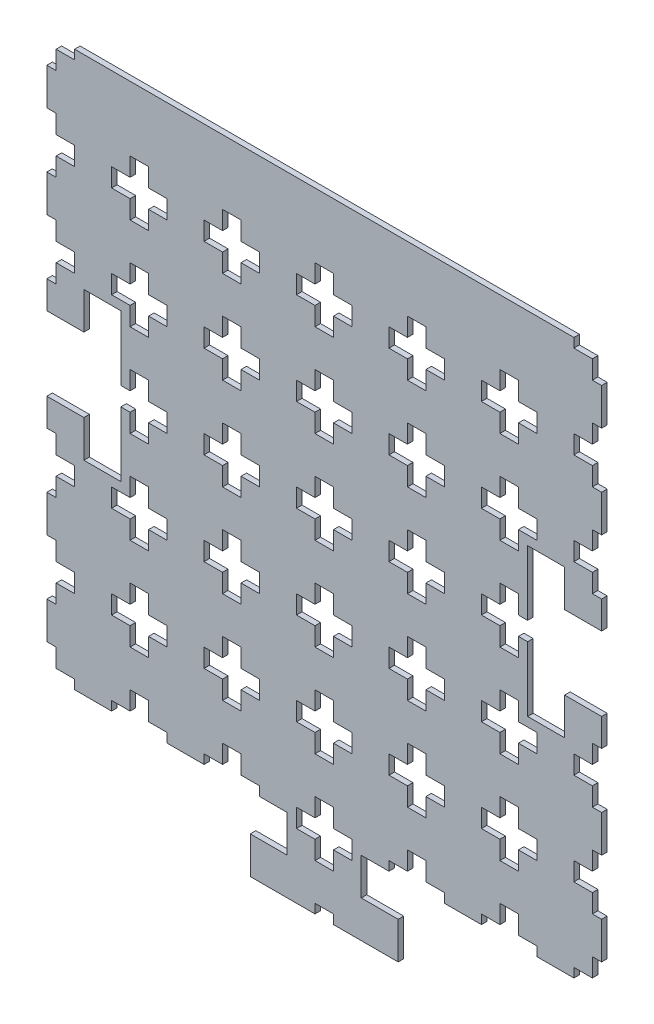
from build123d import *

# Parameters (mm, degrees)
ESQUISSE1_W             = 300
ESQUISSE1_H             = 300
BOSS_EXTRU_1_DEPTH      = 3
BOSS_EXTRU_5_DEPTH      = 3
ENL_V_MAT_EXTRU_4_DEPTH = 4
ENL_V_MAT_EXTRU_5_DEPTH = 4


with BuildPart() as part:
    # Esquisse1 → Boss.-Extru.1 (new body)
    with BuildSketch(Plane.XY):
        with Locations((-68.640329964, 23.061811309)):
            Rectangle(ESQUISSE1_W, ESQUISSE1_H)
    extrude(amount=BOSS_EXTRU_1_DEPTH)

    # Esquisse3 → Boss.-Extru.5 (add)
    with BuildSketch(Plane(origin=(0, 0, 0), x_dir=(-1, 0, 0), z_dir=(0, 0, -1))):
        Polygon((48.640329964, -126.938188691), (48.640329964, -146.938188691), (28.640329964, -146.938188691), (28.640329964, -166.938188691), (108.640329964, -166.938188691), (108.640329964, -146.938188691), (88.640329964, -146.938188691), (88.640329964, -126.938188691), align=None)
    extrude(amount=-BOSS_EXTRU_5_DEPTH)

    # Esquisse4 → Enlèv. mat.-Extru.4 (cut, through all)
    with BuildSketch(Plane.XY.offset(3)):
        Polygon((81.359670036, 3.061811309), (81.359670036, 43.061811309), (61.359670036, 43.061811309), (61.359670036, 63.061811309), (41.359670036, 63.061811309), (41.359670036, -16.938188691), (61.359670036, -16.938188691), (61.359670036, 3.061811309), align=None)
        Polygon((-218.640329964, 43.061811309), (-218.640329964, 3.061811309), (-198.640329964, 3.061811309), (-198.640329964, -16.938188691), (-178.640329964, -16.938188691), (-178.640329964, 63.061811309), (-198.640329964, 63.061811309), (-198.640329964, 43.061811309), align=None)
    extrude(amount=-ENL_V_MAT_EXTRU_4_DEPTH, mode=Mode.SUBTRACT)

    # Esquisse2 → Enlèv. mat.-Extru.5 (cut, through all)
    with BuildSketch(Plane(origin=(0, 0, 0), x_dir=(-1, 0, 0), z_dir=(0, 0, -1))):
        Polygon((-81.359670036, 138.061811309), (-76.359670036, 138.061811309), (-76.359670036, 128.061811309), (-66.359670036, 128.061811309), (-66.359670036, 118.061811309), (-76.359670036, 118.061811309), (-76.359670036, 108.061811309), (-81.359670036, 108.061811309), align=None)
        Polygon((13.640329964, 128.061811309), (13.640329964, 138.061811309), (23.640329964, 138.061811309), (23.640329964, 128.061811309), (33.640329964, 128.061811309), (33.640329964, 118.061811309), (23.640329964, 118.061811309), (23.640329964, 108.061811309), (13.640329964, 108.061811309), (13.640329964, 118.061811309), (3.640329964, 118.061811309), (3.640329964, 128.061811309), align=None)
        Polygon((-81.359670036, 88.061811309), (-76.359670036, 88.061811309), (-76.359670036, 78.061811309), (-66.359670036, 78.061811309), (-66.359670036, 68.061811309), (-76.359670036, 68.061811309), (-76.359670036, 58.061811309), (-81.359670036, 58.061811309), align=None)
        Polygon((-81.359670036, 38.061811309), (-76.359670036, 38.061811309), (-76.359670036, 28.061811309), (-66.359670036, 28.061811309), (-66.359670036, 18.061811309), (-76.359670036, 18.061811309), (-76.359670036, 8.061811309), (-81.359670036, 8.061811309), align=None)
        Polygon((-81.359670036, -11.938188691), (-76.359670036, -11.938188691), (-76.359670036, -21.938188691), (-66.359670036, -21.938188691), (-66.359670036, -31.938188691), (-76.359670036, -31.938188691), (-76.359670036, -41.938188691), (-81.359670036, -41.938188691), align=None)
        Polygon((-81.359670036, -61.938188691), (-76.359670036, -61.938188691), (-76.359670036, -71.938188691), (-66.359670036, -71.938188691), (-66.359670036, -81.938188691), (-76.359670036, -81.938188691), (-76.359670036, -91.938188691), (-81.359670036, -91.938188691), align=None)
        Polygon((-81.359670036, -111.938188691), (-76.359670036, -111.938188691), (-76.359670036, -121.938188691), (-66.359670036, -121.938188691), (-66.359670036, -126.938188691), (-81.359670036, -126.938188691), align=None)
        Polygon((-36.359670036, 128.061811309), (-36.359670036, 138.061811309), (-26.359670036, 138.061811309), (-26.359670036, 128.061811309), (-16.359670036, 128.061811309), (-16.359670036, 118.061811309), (-26.359670036, 118.061811309), (-26.359670036, 108.061811309), (-36.359670036, 108.061811309), (-36.359670036, 118.061811309), (-46.359670036, 118.061811309), (-46.359670036, 128.061811309), align=None)
        Polygon((63.640329964, 128.061811309), (63.640329964, 138.061811309), (73.640329964, 138.061811309), (73.640329964, 128.061811309), (83.640329964, 128.061811309), (83.640329964, 118.061811309), (73.640329964, 118.061811309), (73.640329964, 108.061811309), (63.640329964, 108.061811309), (63.640329964, 118.061811309), (53.640329964, 118.061811309), (53.640329964, 128.061811309), align=None)
        Polygon((113.640329964, 128.061811309), (113.640329964, 138.061811309), (123.640329964, 138.061811309), (123.640329964, 128.061811309), (133.640329964, 128.061811309), (133.640329964, 118.061811309), (123.640329964, 118.061811309), (123.640329964, 108.061811309), (113.640329964, 108.061811309), (113.640329964, 118.061811309), (103.640329964, 118.061811309), (103.640329964, 128.061811309), align=None)
        Polygon((163.640329964, 128.061811309), (163.640329964, 138.061811309), (173.640329964, 138.061811309), (173.640329964, 128.061811309), (183.640329964, 128.061811309), (183.640329964, 118.061811309), (173.640329964, 118.061811309), (173.640329964, 108.061811309), (163.640329964, 108.061811309), (163.640329964, 118.061811309), (153.640329964, 118.061811309), (153.640329964, 128.061811309), align=None)
        Polygon((213.640329964, 128.061811309), (213.640329964, 138.061811309), (223.640329964, 138.061811309), (223.640329964, 128.061811309), (233.640329964, 128.061811309), (233.640329964, 118.061811309), (223.640329964, 118.061811309), (223.640329964, 108.061811309), (213.640329964, 108.061811309), (213.640329964, 118.061811309), (203.640329964, 118.061811309), (203.640329964, 128.061811309), align=None)
        Polygon((13.640329964, 78.061811309), (13.640329964, 88.061811309), (23.640329964, 88.061811309), (23.640329964, 78.061811309), (33.640329964, 78.061811309), (33.640329964, 68.061811309), (23.640329964, 68.061811309), (23.640329964, 58.061811309), (13.640329964, 58.061811309), (13.640329964, 68.061811309), (3.640329964, 68.061811309), (3.640329964, 78.061811309), align=None)
        Polygon((63.640329964, 78.061811309), (63.640329964, 88.061811309), (73.640329964, 88.061811309), (73.640329964, 78.061811309), (83.640329964, 78.061811309), (83.640329964, 68.061811309), (73.640329964, 68.061811309), (73.640329964, 58.061811309), (63.640329964, 58.061811309), (63.640329964, 68.061811309), (53.640329964, 68.061811309), (53.640329964, 78.061811309), align=None)
        Polygon((113.640329964, 78.061811309), (113.640329964, 88.061811309), (123.640329964, 88.061811309), (123.640329964, 78.061811309), (133.640329964, 78.061811309), (133.640329964, 68.061811309), (123.640329964, 68.061811309), (123.640329964, 58.061811309), (113.640329964, 58.061811309), (113.640329964, 68.061811309), (103.640329964, 68.061811309), (103.640329964, 78.061811309), align=None)
        Polygon((163.640329964, 78.061811309), (163.640329964, 88.061811309), (173.640329964, 88.061811309), (173.640329964, 78.061811309), (183.640329964, 78.061811309), (183.640329964, 68.061811309), (173.640329964, 68.061811309), (173.640329964, 58.061811309), (163.640329964, 58.061811309), (163.640329964, 68.061811309), (153.640329964, 68.061811309), (153.640329964, 78.061811309), align=None)
        Polygon((213.640329964, 78.061811309), (213.640329964, 88.061811309), (223.640329964, 88.061811309), (223.640329964, 78.061811309), (233.640329964, 78.061811309), (233.640329964, 68.061811309), (223.640329964, 68.061811309), (223.640329964, 58.061811309), (213.640329964, 58.061811309), (213.640329964, 68.061811309), (203.640329964, 68.061811309), (203.640329964, 78.061811309), align=None)
        Polygon((13.640329964, 28.061811309), (13.640329964, 38.061811309), (23.640329964, 38.061811309), (23.640329964, 28.061811309), (33.640329964, 28.061811309), (33.640329964, 18.061811309), (23.640329964, 18.061811309), (23.640329964, 8.061811309), (13.640329964, 8.061811309), (13.640329964, 18.061811309), (3.640329964, 18.061811309), (3.640329964, 28.061811309), align=None)
        Polygon((63.640329964, 28.061811309), (63.640329964, 38.061811309), (73.640329964, 38.061811309), (73.640329964, 28.061811309), (83.640329964, 28.061811309), (83.640329964, 18.061811309), (73.640329964, 18.061811309), (73.640329964, 8.061811309), (63.640329964, 8.061811309), (63.640329964, 18.061811309), (53.640329964, 18.061811309), (53.640329964, 28.061811309), align=None)
        Polygon((113.640329964, 28.061811309), (113.640329964, 38.061811309), (123.640329964, 38.061811309), (123.640329964, 28.061811309), (133.640329964, 28.061811309), (133.640329964, 18.061811309), (123.640329964, 18.061811309), (123.640329964, 8.061811309), (113.640329964, 8.061811309), (113.640329964, 18.061811309), (103.640329964, 18.061811309), (103.640329964, 28.061811309), align=None)
        Polygon((163.640329964, 28.061811309), (163.640329964, 38.061811309), (173.640329964, 38.061811309), (173.640329964, 28.061811309), (183.640329964, 28.061811309), (183.640329964, 18.061811309), (173.640329964, 18.061811309), (173.640329964, 8.061811309), (163.640329964, 8.061811309), (163.640329964, 18.061811309), (153.640329964, 18.061811309), (153.640329964, 28.061811309), align=None)
        Polygon((213.640329964, 28.061811309), (213.640329964, 38.061811309), (223.640329964, 38.061811309), (223.640329964, 28.061811309), (233.640329964, 28.061811309), (233.640329964, 18.061811309), (223.640329964, 18.061811309), (223.640329964, 8.061811309), (213.640329964, 8.061811309), (213.640329964, 18.061811309), (203.640329964, 18.061811309), (203.640329964, 28.061811309), align=None)
        Polygon((-66.359670036, 173.061811309), (-66.359670036, 168.061811309), (-76.359670036, 168.061811309), (-76.359670036, 158.061811309), (-81.359670036, 158.061811309), (-81.359670036, 173.061811309), align=None)
        Polygon((218.640329964, 158.061811309), (213.640329964, 158.061811309), (213.640329964, 168.061811309), (203.640329964, 168.061811309), (203.640329964, 173.061811309), (218.640329964, 173.061811309), align=None)
        Polygon((13.640329964, -21.938188691), (13.640329964, -11.938188691), (23.640329964, -11.938188691), (23.640329964, -21.938188691), (33.640329964, -21.938188691), (33.640329964, -31.938188691), (23.640329964, -31.938188691), (23.640329964, -41.938188691), (13.640329964, -41.938188691), (13.640329964, -31.938188691), (3.640329964, -31.938188691), (3.640329964, -21.938188691), align=None)
        Polygon((63.640329964, -21.938188691), (63.640329964, -11.938188691), (73.640329964, -11.938188691), (73.640329964, -21.938188691), (83.640329964, -21.938188691), (83.640329964, -31.938188691), (73.640329964, -31.938188691), (73.640329964, -41.938188691), (63.640329964, -41.938188691), (63.640329964, -31.938188691), (53.640329964, -31.938188691), (53.640329964, -21.938188691), align=None)
        Polygon((113.640329964, -21.938188691), (113.640329964, -11.938188691), (123.640329964, -11.938188691), (123.640329964, -21.938188691), (133.640329964, -21.938188691), (133.640329964, -31.938188691), (123.640329964, -31.938188691), (123.640329964, -41.938188691), (113.640329964, -41.938188691), (113.640329964, -31.938188691), (103.640329964, -31.938188691), (103.640329964, -21.938188691), align=None)
        Polygon((163.640329964, -21.938188691), (163.640329964, -11.938188691), (173.640329964, -11.938188691), (173.640329964, -21.938188691), (183.640329964, -21.938188691), (183.640329964, -31.938188691), (173.640329964, -31.938188691), (173.640329964, -41.938188691), (163.640329964, -41.938188691), (163.640329964, -31.938188691), (153.640329964, -31.938188691), (153.640329964, -21.938188691), align=None)
        Polygon((213.640329964, -21.938188691), (213.640329964, -11.938188691), (223.640329964, -11.938188691), (223.640329964, -21.938188691), (233.640329964, -21.938188691), (233.640329964, -31.938188691), (223.640329964, -31.938188691), (223.640329964, -41.938188691), (213.640329964, -41.938188691), (213.640329964, -31.938188691), (203.640329964, -31.938188691), (203.640329964, -21.938188691), align=None)
        Polygon((13.640329964, -71.938188691), (13.640329964, -61.938188691), (23.640329964, -61.938188691), (23.640329964, -71.938188691), (33.640329964, -71.938188691), (33.640329964, -81.938188691), (23.640329964, -81.938188691), (23.640329964, -91.938188691), (13.640329964, -91.938188691), (13.640329964, -81.938188691), (3.640329964, -81.938188691), (3.640329964, -71.938188691), align=None)
        Polygon((63.640329964, -71.938188691), (63.640329964, -61.938188691), (73.640329964, -61.938188691), (73.640329964, -71.938188691), (83.640329964, -71.938188691), (83.640329964, -81.938188691), (73.640329964, -81.938188691), (73.640329964, -91.938188691), (63.640329964, -91.938188691), (63.640329964, -81.938188691), (53.640329964, -81.938188691), (53.640329964, -71.938188691), align=None)
        Polygon((113.640329964, -71.938188691), (113.640329964, -61.938188691), (123.640329964, -61.938188691), (123.640329964, -71.938188691), (133.640329964, -71.938188691), (133.640329964, -81.938188691), (123.640329964, -81.938188691), (123.640329964, -91.938188691), (113.640329964, -91.938188691), (113.640329964, -81.938188691), (103.640329964, -81.938188691), (103.640329964, -71.938188691), align=None)
        Polygon((163.640329964, -71.938188691), (163.640329964, -61.938188691), (173.640329964, -61.938188691), (173.640329964, -71.938188691), (183.640329964, -71.938188691), (183.640329964, -81.938188691), (173.640329964, -81.938188691), (173.640329964, -91.938188691), (163.640329964, -91.938188691), (163.640329964, -81.938188691), (153.640329964, -81.938188691), (153.640329964, -71.938188691), align=None)
        Polygon((213.640329964, -71.938188691), (213.640329964, -61.938188691), (223.640329964, -61.938188691), (223.640329964, -71.938188691), (233.640329964, -71.938188691), (233.640329964, -81.938188691), (223.640329964, -81.938188691), (223.640329964, -91.938188691), (213.640329964, -91.938188691), (213.640329964, -81.938188691), (203.640329964, -81.938188691), (203.640329964, -71.938188691), align=None)
        Polygon((13.640329964, -121.938188691), (13.640329964, -111.938188691), (23.640329964, -111.938188691), (23.640329964, -121.938188691), (33.640329964, -121.938188691), (33.640329964, -131.938188691), (23.640329964, -131.938188691), (23.640329964, -141.938188691), (13.640329964, -141.938188691), (13.640329964, -131.938188691), (3.640329964, -131.938188691), (3.640329964, -121.938188691), align=None)
        Polygon((63.640329964, -121.938188691), (63.640329964, -111.938188691), (73.640329964, -111.938188691), (73.640329964, -121.938188691), (83.640329964, -121.938188691), (83.640329964, -131.938188691), (73.640329964, -131.938188691), (73.640329964, -141.938188691), (63.640329964, -141.938188691), (63.640329964, -131.938188691), (53.640329964, -131.938188691), (53.640329964, -121.938188691), align=None)
        Polygon((113.640329964, -121.938188691), (113.640329964, -111.938188691), (123.640329964, -111.938188691), (123.640329964, -121.938188691), (133.640329964, -121.938188691), (133.640329964, -131.938188691), (123.640329964, -131.938188691), (123.640329964, -141.938188691), (113.640329964, -141.938188691), (113.640329964, -131.938188691), (103.640329964, -131.938188691), (103.640329964, -121.938188691), align=None)
        Polygon((163.640329964, -121.938188691), (163.640329964, -111.938188691), (173.640329964, -111.938188691), (173.640329964, -121.938188691), (183.640329964, -121.938188691), (183.640329964, -131.938188691), (173.640329964, -131.938188691), (173.640329964, -141.938188691), (163.640329964, -141.938188691), (163.640329964, -131.938188691), (153.640329964, -131.938188691), (153.640329964, -121.938188691), align=None)
        Polygon((213.640329964, -121.938188691), (213.640329964, -111.938188691), (223.640329964, -111.938188691), (223.640329964, -121.938188691), (233.640329964, -121.938188691), (233.640329964, -131.938188691), (223.640329964, -131.938188691), (223.640329964, -141.938188691), (213.640329964, -141.938188691), (213.640329964, -131.938188691), (203.640329964, -131.938188691), (203.640329964, -121.938188691), align=None)
        Polygon((13.640329964, -171.938188691), (13.640329964, -161.938188691), (23.640329964, -161.938188691), (23.640329964, -171.938188691), (33.640329964, -171.938188691), (33.640329964, -181.938188691), (23.640329964, -181.938188691), (23.640329964, -191.938188691), (13.640329964, -191.938188691), (13.640329964, -181.938188691), (3.640329964, -181.938188691), (3.640329964, -171.938188691), align=None)
        Polygon((63.640329964, -171.938188691), (63.640329964, -161.938188691), (73.640329964, -161.938188691), (73.640329964, -171.938188691), (83.640329964, -171.938188691), (83.640329964, -181.938188691), (73.640329964, -181.938188691), (73.640329964, -191.938188691), (63.640329964, -191.938188691), (63.640329964, -181.938188691), (53.640329964, -181.938188691), (53.640329964, -171.938188691), align=None)
        Polygon((113.640329964, -171.938188691), (113.640329964, -161.938188691), (123.640329964, -161.938188691), (123.640329964, -171.938188691), (133.640329964, -171.938188691), (133.640329964, -181.938188691), (123.640329964, -181.938188691), (123.640329964, -191.938188691), (113.640329964, -191.938188691), (113.640329964, -181.938188691), (103.640329964, -181.938188691), (103.640329964, -171.938188691), align=None)
        Polygon((63.640329964, -221.938188691), (63.640329964, -211.938188691), (73.640329964, -211.938188691), (73.640329964, -221.938188691), (83.640329964, -221.938188691), (83.640329964, -231.938188691), (73.640329964, -231.938188691), (73.640329964, -241.938188691), (63.640329964, -241.938188691), (63.640329964, -231.938188691), (53.640329964, -231.938188691), (53.640329964, -221.938188691), align=None)
        Polygon((-36.359670036, 78.061811309), (-36.359670036, 88.061811309), (-26.359670036, 88.061811309), (-26.359670036, 78.061811309), (-16.359670036, 78.061811309), (-16.359670036, 68.061811309), (-26.359670036, 68.061811309), (-26.359670036, 58.061811309), (-36.359670036, 58.061811309), (-36.359670036, 68.061811309), (-46.359670036, 68.061811309), (-46.359670036, 78.061811309), align=None)
        Polygon((-36.359670036, 28.061811309), (-36.359670036, 38.061811309), (-26.359670036, 38.061811309), (-26.359670036, 28.061811309), (-16.359670036, 28.061811309), (-16.359670036, 18.061811309), (-26.359670036, 18.061811309), (-26.359670036, 8.061811309), (-36.359670036, 8.061811309), (-36.359670036, 18.061811309), (-46.359670036, 18.061811309), (-46.359670036, 28.061811309), align=None)
        Polygon((-36.359670036, -21.938188691), (-36.359670036, -11.938188691), (-26.359670036, -11.938188691), (-26.359670036, -21.938188691), (-16.359670036, -21.938188691), (-16.359670036, -31.938188691), (-26.359670036, -31.938188691), (-26.359670036, -41.938188691), (-36.359670036, -41.938188691), (-36.359670036, -31.938188691), (-46.359670036, -31.938188691), (-46.359670036, -21.938188691), align=None)
        Polygon((-36.359670036, -71.938188691), (-36.359670036, -61.938188691), (-26.359670036, -61.938188691), (-26.359670036, -71.938188691), (-16.359670036, -71.938188691), (-16.359670036, -81.938188691), (-26.359670036, -81.938188691), (-26.359670036, -91.938188691), (-36.359670036, -91.938188691), (-36.359670036, -81.938188691), (-46.359670036, -81.938188691), (-46.359670036, -71.938188691), align=None)
        Polygon((-36.359670036, -121.938188691), (-36.359670036, -111.938188691), (-26.359670036, -111.938188691), (-26.359670036, -121.938188691), (-16.359670036, -121.938188691), (-16.359670036, -131.938188691), (-26.359670036, -131.938188691), (-26.359670036, -141.938188691), (-36.359670036, -141.938188691), (-36.359670036, -131.938188691), (-46.359670036, -131.938188691), (-46.359670036, -121.938188691), align=None)
    extrude(amount=-ENL_V_MAT_EXTRU_5_DEPTH, mode=Mode.SUBTRACT)


solid = part.part
